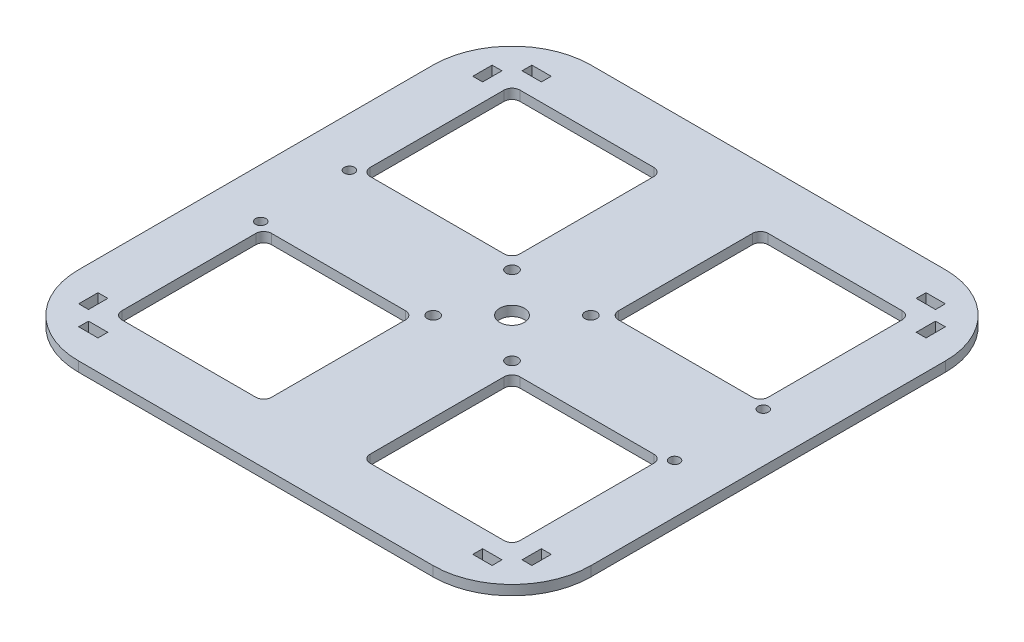
from build123d import *

# Parameters (mm, degrees)
SKETCH2_R           = 7.9375
SKETCH2_R_2         = 3.81
SKETCH2_R_3         = 3.302
SKETCH2_W           = 12.446
SKETCH2_H           = 6.35
SKETCH2_W_2         = 6.35
SKETCH2_H_2         = 12.446
BOSS_EXTRUDE1_DEPTH = 6.35


with BuildPart() as part:
    # Sketch2 → Boss-Extrude1 (new body)
    with BuildSketch(Plane(origin=(0, 0, 0), x_dir=(1, 0, 0), z_dir=(0, 1, 0))):
        with BuildLine():
            Line((-114.3, -165.1), (114.3, -165.1))
            ThreePointArc((114.3, -165.1), (150.221024484, -150.221024484), (165.1, -114.3))
            Line((165.1, -114.3), (165.1, 114.3))
            ThreePointArc((165.1, 114.3), (150.221024484, 150.221024484), (114.3, 165.1))
            Line((114.3, 165.1), (-114.3, 165.1))
            ThreePointArc((-114.3, 165.1), (-150.221024484, 150.221024484), (-165.1, 114.3))
            Line((-165.1, 114.3), (-165.1, -114.3))
            ThreePointArc((-165.1, -114.3), (-150.221024484, -150.221024484), (-114.3, -165.1))
        make_face()
        Circle(SKETCH2_R, mode=Mode.SUBTRACT)
        with Locations((25.4, -25.4)):
            Circle(SKETCH2_R_2, mode=Mode.SUBTRACT)
        with Locations((25.4, 25.4)):
            Circle(SKETCH2_R_2, mode=Mode.SUBTRACT)
        with Locations((-25.4, 25.4)):
            Circle(SKETCH2_R_2, mode=Mode.SUBTRACT)
        with Locations((-25.4, -25.4)):
            Circle(SKETCH2_R_2, mode=Mode.SUBTRACT)
        with Locations((133.35, -28.575)):
            Circle(SKETCH2_R_3, mode=Mode.SUBTRACT)
        with Locations((-133.35, -28.575)):
            Circle(SKETCH2_R_3, mode=Mode.SUBTRACT)
        with Locations((-133.35, 28.575)):
            Circle(SKETCH2_R_3, mode=Mode.SUBTRACT)
        with Locations((133.35, 28.575)):
            Circle(SKETCH2_R_3, mode=Mode.SUBTRACT)
        with BuildLine():
            Line((-123.19, 128.27), (-36.83, 128.27))
            ThreePointArc((-36.83, 128.27), (-33.237897552, 126.782102448), (-31.75, 123.19))
            Line((-31.75, 123.19), (-31.75, 36.83))
            ThreePointArc((-31.75, 36.83), (-33.237897552, 33.237897552), (-36.83, 31.75))
            Line((-36.83, 31.75), (-123.19, 31.75))
            ThreePointArc((-123.19, 31.75), (-126.782102448, 33.237897552), (-128.27, 36.83))
            Line((-128.27, 36.83), (-128.27, 123.19))
            ThreePointArc((-128.27, 123.19), (-126.782102448, 126.782102448), (-123.19, 128.27))
        make_face(mode=Mode.SUBTRACT)
        with BuildLine():
            Line((36.83, 128.27), (123.19, 128.27))
            ThreePointArc((123.19, 128.27), (126.782102448, 126.782102448), (128.27, 123.19))
            Line((128.27, 123.19), (128.27, 36.83))
            ThreePointArc((128.27, 36.83), (126.782102448, 33.237897552), (123.19, 31.75))
            Line((123.19, 31.75), (36.83, 31.75))
            ThreePointArc((36.83, 31.75), (33.237897552, 33.237897552), (31.75, 36.83))
            Line((31.75, 36.83), (31.75, 123.19))
            ThreePointArc((31.75, 123.19), (33.237897552, 126.782102448), (36.83, 128.27))
        make_face(mode=Mode.SUBTRACT)
        with BuildLine():
            Line((-123.19, -31.75), (-36.83, -31.75))
            ThreePointArc((-36.83, -31.75), (-33.237897552, -33.237897552), (-31.75, -36.83))
            Line((-31.75, -36.83), (-31.75, -123.19))
            ThreePointArc((-31.75, -123.19), (-33.237897552, -126.782102448), (-36.83, -128.27))
            Line((-36.83, -128.27), (-123.19, -128.27))
            ThreePointArc((-123.19, -128.27), (-126.782102448, -126.782102448), (-128.27, -123.19))
            Line((-128.27, -123.19), (-128.27, -36.83))
            ThreePointArc((-128.27, -36.83), (-126.782102448, -33.237897552), (-123.19, -31.75))
        make_face(mode=Mode.SUBTRACT)
        with BuildLine():
            Line((36.83, -31.75), (123.19, -31.75))
            ThreePointArc((123.19, -31.75), (126.782102448, -33.237897552), (128.27, -36.83))
            Line((128.27, -36.83), (128.27, -123.19))
            ThreePointArc((128.27, -123.19), (126.782102448, -126.782102448), (123.19, -128.27))
            Line((123.19, -128.27), (36.83, -128.27))
            ThreePointArc((36.83, -128.27), (33.237897552, -126.782102448), (31.75, -123.19))
            Line((31.75, -123.19), (31.75, -36.83))
            ThreePointArc((31.75, -36.83), (33.237897552, -33.237897552), (36.83, -31.75))
        make_face(mode=Mode.SUBTRACT)
        with Locations((-127, -142.875)):
            Rectangle(SKETCH2_W, SKETCH2_H, mode=Mode.SUBTRACT)
        with Locations((127, -142.875)):
            Rectangle(SKETCH2_W, SKETCH2_H, mode=Mode.SUBTRACT)
        with Locations((-142.875, 127)):
            Rectangle(SKETCH2_W_2, SKETCH2_H_2, mode=Mode.SUBTRACT)
        with Locations((-142.875, -127)):
            Rectangle(SKETCH2_W_2, SKETCH2_H_2, mode=Mode.SUBTRACT)
        with Locations((127, 142.875)):
            Rectangle(SKETCH2_W, SKETCH2_H, mode=Mode.SUBTRACT)
        with Locations((-127, 142.875)):
            Rectangle(SKETCH2_W, SKETCH2_H, mode=Mode.SUBTRACT)
        with Locations((142.875, -127)):
            Rectangle(SKETCH2_W_2, SKETCH2_H_2, mode=Mode.SUBTRACT)
        with Locations((142.875, 127)):
            Rectangle(SKETCH2_W_2, SKETCH2_H_2, mode=Mode.SUBTRACT)
    extrude(amount=BOSS_EXTRUDE1_DEPTH)


solid = part.part
